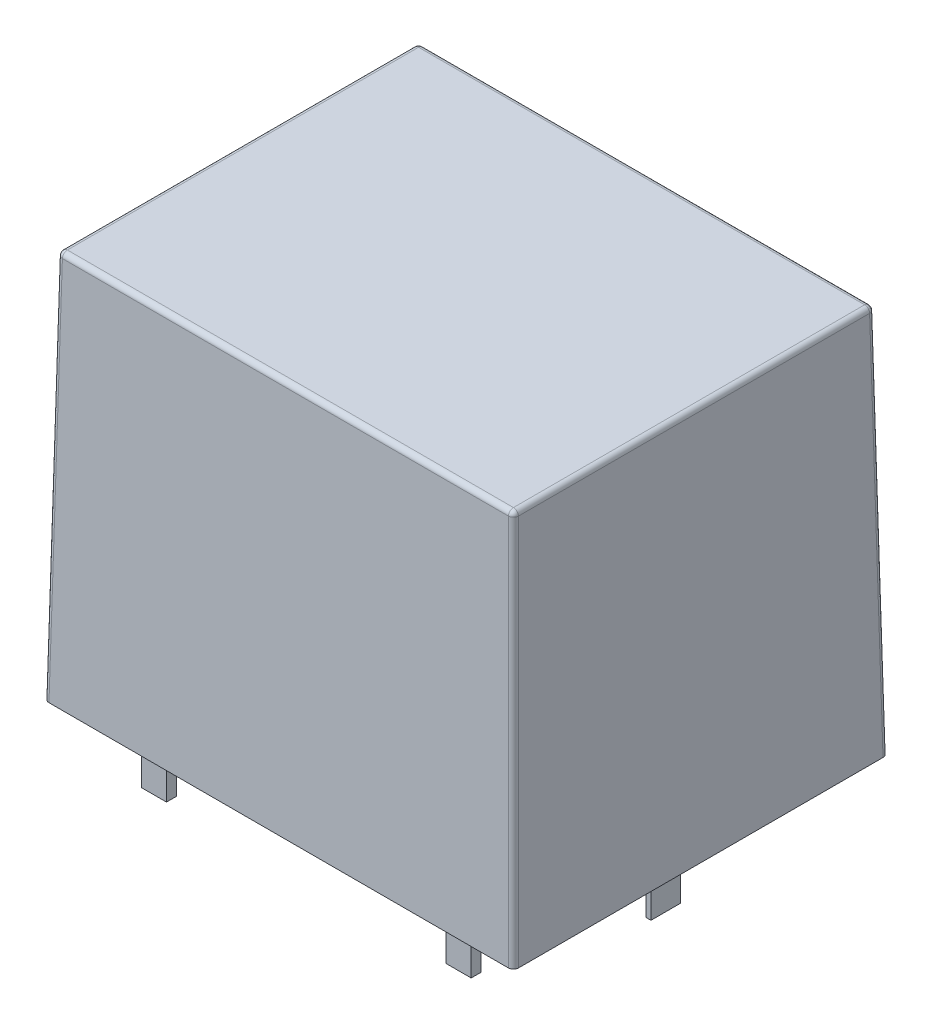
from build123d import *

# Parameters (mm, degrees)
SKETCH1_W           = 18.8
SKETCH1_H           = 15
BOSS_EXTRUDE1_DEPTH = 15.6
BOSS_EXTRUDE1_TAPER = 1
FILLET1_R           = 0.2
SKETCH2_W           = 1
SKETCH2_H           = 0.4
SKETCH2_W_2         = 0.2
SKETCH2_H_2         = 1.190908677
SKETCH2_H_3         = 0.45383017
BOSS_EXTRUDE2_DEPTH = 3


with BuildPart() as part:
    # Sketch1 → Boss-Extrude1 (new body)
    with BuildSketch(Plane(origin=(0, 0, 0), x_dir=(1, 0, 0), z_dir=(0, 1, 0))):
        with Locations((0, -0.606666667)):
            Rectangle(SKETCH1_W, SKETCH1_H)
    extrude(amount=BOSS_EXTRUDE1_DEPTH, taper=BOSS_EXTRUDE1_TAPER)

    # Fillet1
    fillet1_edges = [part.edges().sort_by_distance(p)[0] for p in [
        (9.127700987, 15.6, 0.606666667),
        (0, 15.6, -6.62103432),
        (-9.127700987, 15.6, 0.606666667),
        (0, 15.6, 7.834367654),
        (-9.263850494, 7.8, -6.757183827),
        (9.263850494, 7.8, -6.757183827),
        (9.263850494, 7.8, 7.97051716),
        (-9.263850494, 7.8, 7.97051716),
    ]]
    fillet(fillet1_edges, radius=FILLET1_R)

    # Sketch2 → Boss-Extrude2 (add)
    with BuildSketch(Plane(origin=(0, 0, 0), x_dir=(-1, 0, 0), z_dir=(0, -1, 0))):
        with Locations((-5.3, -6)):
            Rectangle(SKETCH2_W, SKETCH2_H)
        with Locations((-7.3, -0.004545662)):
            Rectangle(SKETCH2_W_2, SKETCH2_H_2)
        with Locations((6.9, -6)):
            Rectangle(SKETCH2_W, SKETCH2_H)
        with Locations((-5.3, 5.973084915)):
            Rectangle(SKETCH2_W, SKETCH2_H_3)
        with Locations((6.9, 6)):
            Rectangle(SKETCH2_W, SKETCH2_H)
    extrude(amount=BOSS_EXTRUDE2_DEPTH)


solid = part.part
